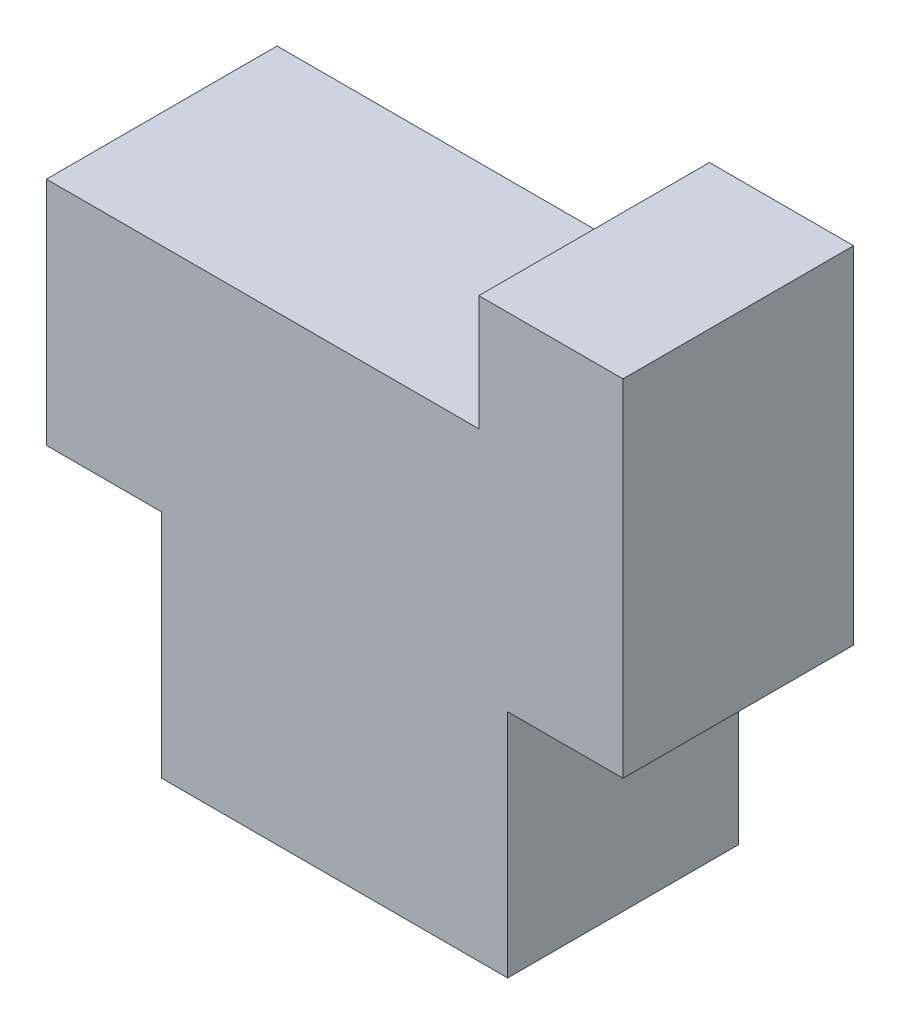
from build123d import *

# Parameters (mm, degrees)
BOSS_EXTRUDE1_DEPTH = 4


with BuildPart() as part:
    # Sketch1 → Boss-Extrude1 (new body)
    with BuildSketch(Plane.XY):
        Polygon((0, 0), (6, 0), (6, 4), (8, 4), (8, 10), (5.5, 10), (5.5, 8), (-2, 8), (-2, 4), (0, 4), align=None)
    extrude(amount=BOSS_EXTRUDE1_DEPTH)


solid = part.part
